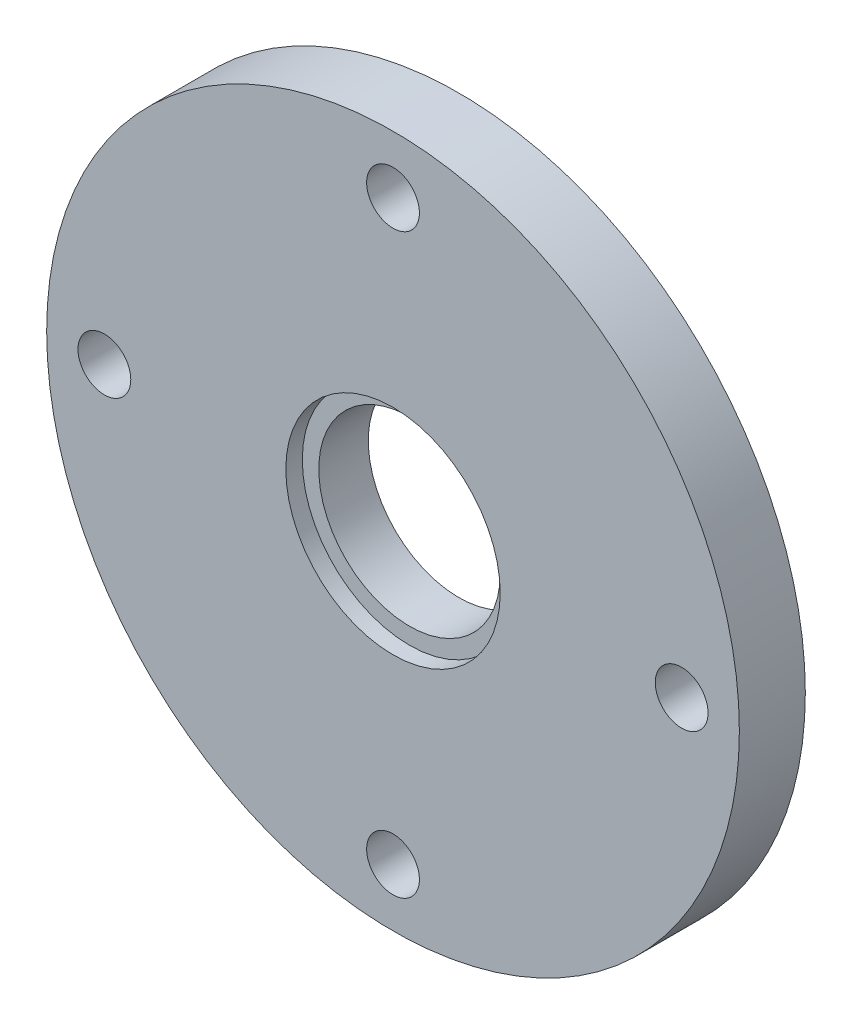
from build123d import *

# Parameters (mm, degrees)
SKETCH1_R                                       = 21
SKETCH1_R_2                                     = 1.6
SKETCH1_R_3                                     = 5.5
BOSS_EXTRUDE1_DEPTH                             = 4
SKETCH2_R                                       = 6.5
CUT_EXTRUDE1_DEPTH                              = 1
CSK_FOR_M3_FLAT_HEAD_MACHINE_SCREW1_D           = 3.2
CSK_FOR_M3_FLAT_HEAD_MACHINE_SCREW1_CSINK_D     = 6.3
CSK_FOR_M3_FLAT_HEAD_MACHINE_SCREW1_CSINK_ANGLE = 90


with BuildPart() as part:
    # Sketch1 → Boss-Extrude1 (new body)
    with BuildSketch(Plane.XY):
        Circle(SKETCH1_R)
        with Locations((0, 17.5)):
            Circle(SKETCH1_R_2, mode=Mode.SUBTRACT)
        with Locations((17.5, 0)):
            Circle(SKETCH1_R_2, mode=Mode.SUBTRACT)
        with Locations((0, -17.5)):
            Circle(SKETCH1_R_2, mode=Mode.SUBTRACT)
        with Locations((-17.5, 0)):
            Circle(SKETCH1_R_2, mode=Mode.SUBTRACT)
        Circle(SKETCH1_R_3, mode=Mode.SUBTRACT)
    extrude(amount=BOSS_EXTRUDE1_DEPTH)

    # Sketch2 → Cut-Extrude1 (cut)
    with BuildSketch(Plane.XY.offset(4)):
        Circle(SKETCH2_R)
    extrude(amount=-CUT_EXTRUDE1_DEPTH, mode=Mode.SUBTRACT)

    # CSK for M3 Flat Head Machine Screw1 (through all)
    with Locations(Plane(origin=(0, 0, 0), x_dir=(-1, 0, 0), z_dir=(0, 0, -1))):
        with Locations((17.5, 0), (0, 17.5), (-17.5, 0), (0, -17.5)):
            CounterSinkHole(CSK_FOR_M3_FLAT_HEAD_MACHINE_SCREW1_D / 2, CSK_FOR_M3_FLAT_HEAD_MACHINE_SCREW1_CSINK_D / 2, counter_sink_angle=CSK_FOR_M3_FLAT_HEAD_MACHINE_SCREW1_CSINK_ANGLE)


solid = part.part
